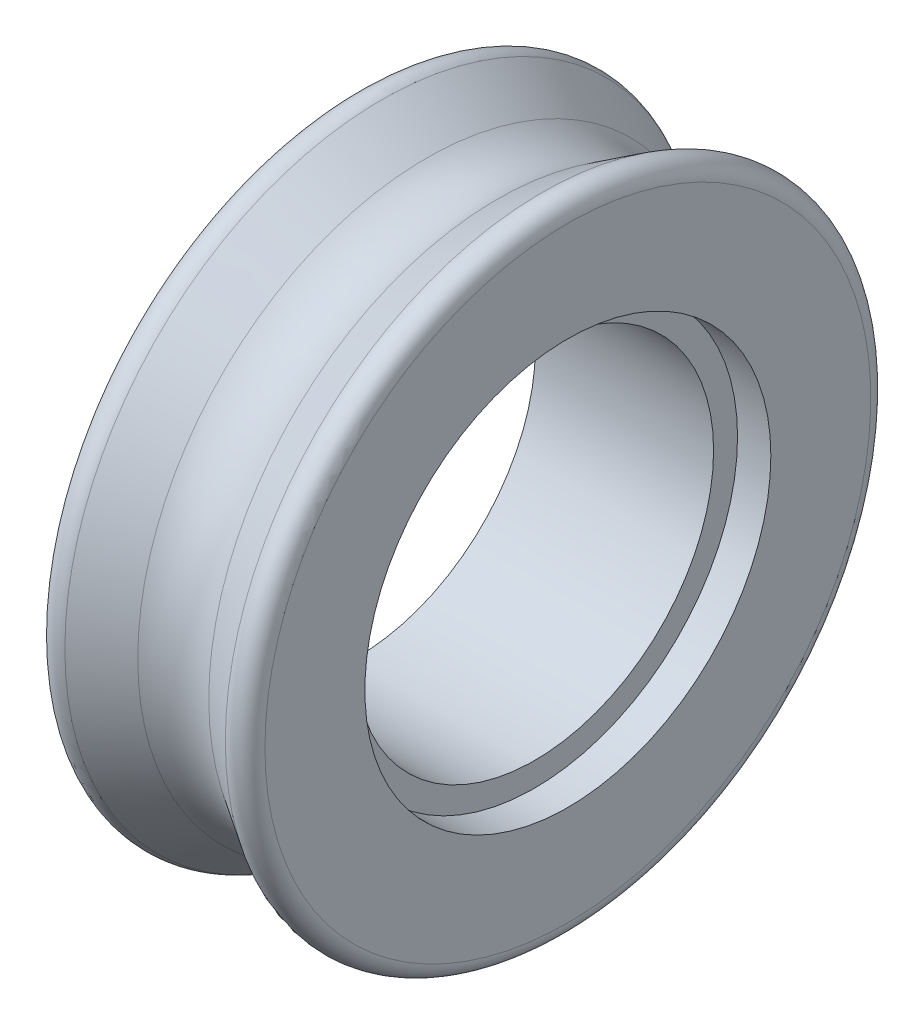
from build123d import *

# Parameters (mm, degrees)
FILLET1_R          = 0.5
FILLET2_R          = 2
SKETCH2_R          = 6.094107734
CUT_EXTRUDE1_DEPTH = 1
SKETCH3_R          = 5.375
CUT_EXTRUDE2_DEPTH = 6.35


with BuildPart() as part:
    # Sketch1 → Revolve1 (revolve)
    with BuildSketch(Plane.XY):
        Polygon((0, 0), (6.35, 0), (6.35, 10), (3.175, 8), (0, 10), align=None)
    revolve(axis=Axis((0, 0, 0), (1, 0, 0)))

    # Fillet1
    fillet1_edges = [part.edges().sort_by_distance(p)[0] for p in [
        (0, -10, 0),
        (6.35, -10, 0),
    ]]
    fillet(fillet1_edges, radius=FILLET1_R)

    # Fillet2
    fillet2_edges = [part.edges().sort_by_distance(p)[0] for p in [
        (3.175, -8, 0),
    ]]
    fillet(fillet2_edges, radius=FILLET2_R)

    # Sketch2 → Cut-Extrude1 (cut)
    with BuildSketch(Plane(origin=(6.35, 0, 0), x_dir=(0, 0, -1), z_dir=(1, 0, 0))):
        Circle(SKETCH2_R)
    extrude(amount=-CUT_EXTRUDE1_DEPTH, mode=Mode.SUBTRACT)

    # Sketch3 → Cut-Extrude2 (cut, through all)
    with BuildSketch(Plane(origin=(5.35, 0, 0), x_dir=(0, 0, -1), z_dir=(1, 0, 0))):
        Circle(SKETCH3_R)
    extrude(amount=-CUT_EXTRUDE2_DEPTH, mode=Mode.SUBTRACT)


solid = part.part
